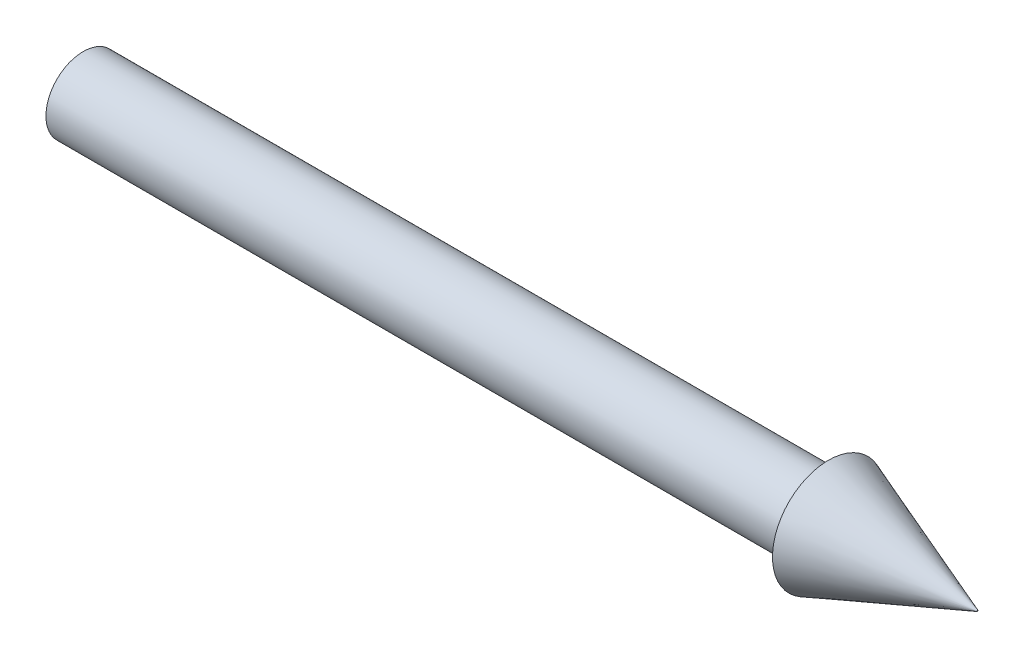
from build123d import *

# Parameters (mm, degrees)
SKETCH1_R           = 12.7
BOSS_EXTRUDE1_DEPTH = 127
SKETCH2_R           = 19.05
SKETCH3_R           = 0.1984375


with BuildPart() as part:
    # Sketch1 → Boss-Extrude1 (new body, symmetric)
    with BuildSketch(Plane(origin=(0, 0, 0), x_dir=(0, 0, -1), z_dir=(1, 0, 0))):
        Circle(SKETCH1_R)
    extrude(amount=BOSS_EXTRUDE1_DEPTH, both=True)

    # Sketch2 → Loft1 section 0
    with BuildSketch(Plane(origin=(127, 0, 0), x_dir=(0, 0, -1), z_dir=(1, 0, 0))):
        Circle(SKETCH2_R)
    # Sketch3 → Loft1 section 1
    with BuildSketch(Plane(origin=(177.8, 0, 0), x_dir=(0, 0, -1), z_dir=(1, 0, 0))):
        Circle(SKETCH3_R)
    loft()


solid = part.part
